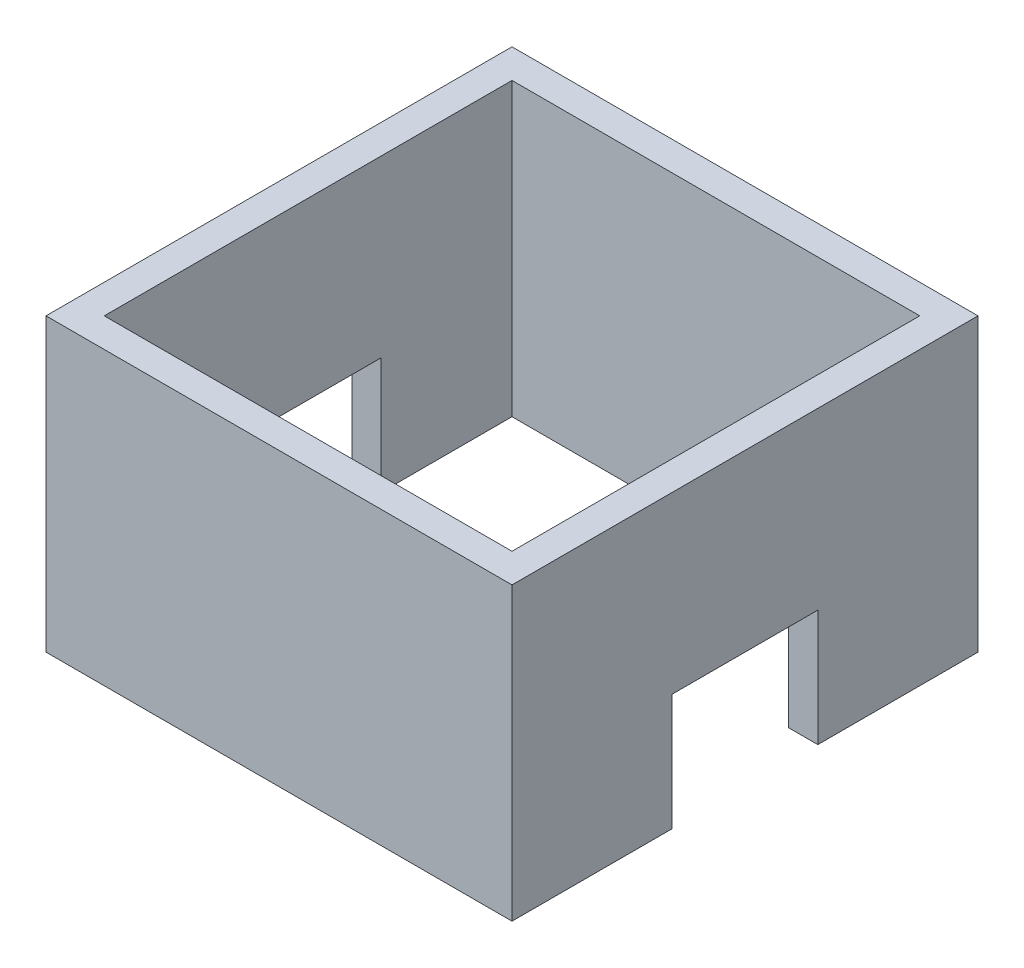
from build123d import *

# Parameters (mm, degrees)
SKETCH1_W           = 32
SKETCH1_H           = 32
SKETCH1_W_2         = 28
SKETCH1_H_2         = 28
BOSS_EXTRUDE1_DEPTH = 20
SKETCH2_W           = 10
SKETCH2_H           = 8
CUT_EXTRUDE1_DEPTH  = 33


with BuildPart() as part:
    # Sketch1 → Boss-Extrude1 (new body)
    with BuildSketch(Plane(origin=(0, 0, 0), x_dir=(1, 0, 0), z_dir=(0, 1, 0))):
        Rectangle(SKETCH1_W, SKETCH1_H)
        Rectangle(SKETCH1_W_2, SKETCH1_H_2, mode=Mode.SUBTRACT)
    extrude(amount=BOSS_EXTRUDE1_DEPTH)

    # Sketch2 → Cut-Extrude1 (cut, through all)
    with BuildSketch(Plane(origin=(16, 0, 0), x_dir=(0, 0, -1), z_dir=(1, 0, 0))):
        with Locations((0, 4)):
            Rectangle(SKETCH2_W, SKETCH2_H)
    extrude(amount=-CUT_EXTRUDE1_DEPTH, mode=Mode.SUBTRACT)


solid = part.part
